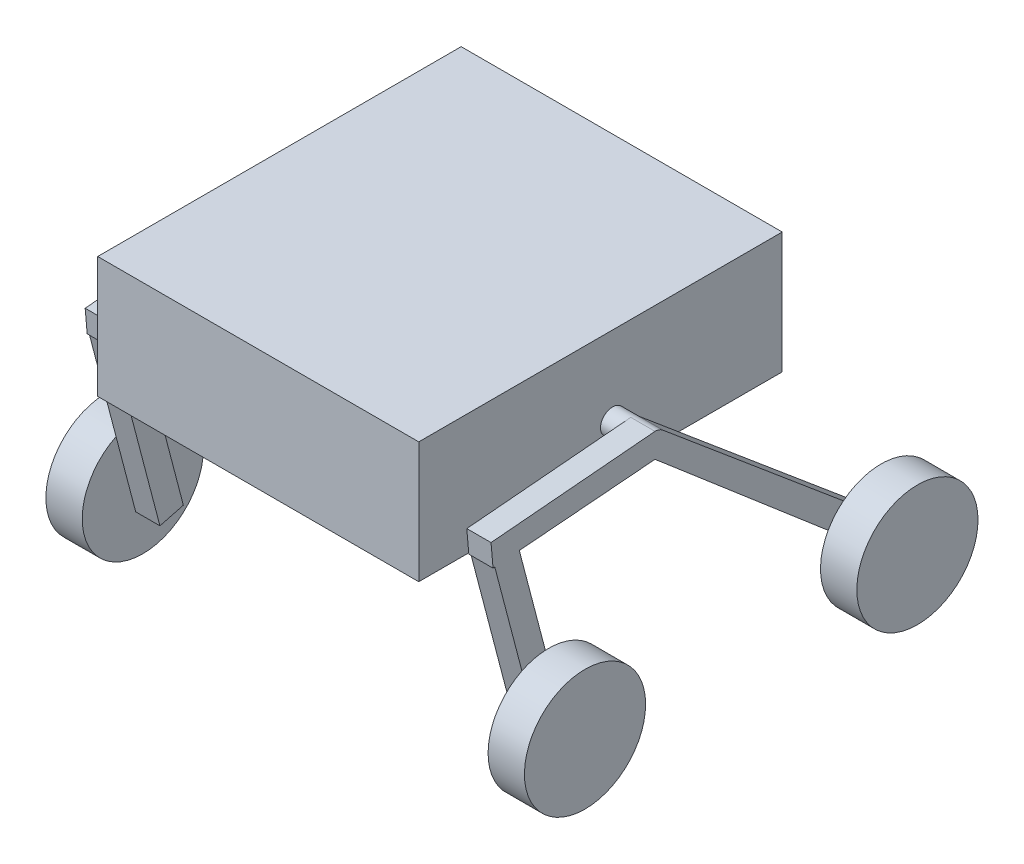
from build123d import *
from build123d.topology import SkipClean

# Parameters (mm, degrees)
SKETCH1_W           = 673.1
SKETCH1_H           = 762
BOSS_EXTRUDE1_DEPTH = 254
SKETCH2_R           = 25.4
BOSS_EXTRUDE2_DEPTH = 38.1
BOSS_EXTRUDE3_DEPTH = 50.8
SKETCH4_R           = 127
BOSS_EXTRUDE4_DEPTH = 76.2


with BuildPart() as part:
    # Sketch1 → Boss-Extrude1 (new body)
    with BuildSketch(Plane(origin=(0, 0, 0), x_dir=(1, 0, 0), z_dir=(0, 1, 0))):
        with Locations((336.55, 381)):
            Rectangle(SKETCH1_W, SKETCH1_H)
    extrude(amount=BOSS_EXTRUDE1_DEPTH)

    # Sketch2 → Boss-Extrude2 (add)
    with BuildSketch(Plane(origin=(673.1, 0, 0), x_dir=(0, 0, -1), z_dir=(1, 0, 0))):
        with Locations((406.4, 88.9)):
            Circle(SKETCH2_R)
    boss_extrude2 = extrude(amount=BOSS_EXTRUDE2_DEPTH)

    # Sketch3 → Boss-Extrude3 (add)
    with SkipClean():  # the faces are left unmerged after this step: merging them gives an invalid solid
        with BuildSketch(Plane(origin=(711.2, 0, 0), x_dir=(0, 0, -1), z_dir=(1, 0, 0))):
            with BuildLine():
                Line((422.726805286, 108.357528855), (925.855623983, -313.817677348))
                Line((925.855623983, -313.817677348), (909.528818697, -333.275206203))
                Line((909.528818697, -333.275206203), (893.202013411, -352.732735059))
                Line((893.202013411, -352.732735059), (406.4, 63.5))
                Line((406.4, 63.5), (121.876807164, 40.194732275))
                Line((121.876807164, 40.194732275), (217.686843741, -325.462787901))
                Line((217.686843741, -325.462787901), (193.116290848, -331.90079462))
                Line((193.116290848, -331.90079462), (168.545737954, -338.338801338))
                Line((168.545737954, -338.338801338), (70.465312804, 35.98362165))
                Line((70.465312804, 35.98362165), (66.845699755, 35.687139489))
                Line((66.845699755, 35.687139489), (64.804838024, 59.014295812))
                Line((64.804838024, 59.014295812), (62.591082159, 84.317641143))
                Line((62.591082159, 84.317641143), (406.4, 114.3))
                ThreePointArc((406.4, 114.3), (415.08731164, 112.768192568), (422.726805286, 108.357528855))
            make_face()
        boss_extrude3 = extrude(amount=BOSS_EXTRUDE3_DEPTH)

    # Sketch4 → Boss-Extrude4 (add)
    with SkipClean():  # the faces are left unmerged after this step: merging them gives an invalid solid
        with BuildSketch(Plane(origin=(762, 0, 0), x_dir=(0, 0, -1), z_dir=(1, 0, 0))):
            with Locations((183.45928077, -295.044965279)):
                Circle(SKETCH4_R)
            with Locations((880.342525414, -308.784998274)):
                Circle(SKETCH4_R)
        boss_extrude4 = extrude(amount=BOSS_EXTRUDE4_DEPTH)

    # Mirror1: Boss-Extrude2, Boss-Extrude3, Boss-Extrude4 across plane
    with SkipClean():  # the faces are left unmerged after this step: merging them gives an invalid solid
        add(boss_extrude2.mirror(Plane(origin=(336.55, 0, 0), x_dir=(0, 0, 1), z_dir=(1, 0, 0))))
        add(boss_extrude3.mirror(Plane(origin=(336.55, 0, 0), x_dir=(0, 0, 1), z_dir=(1, 0, 0))))
        add(boss_extrude4.mirror(Plane(origin=(336.55, 0, 0), x_dir=(0, 0, 1), z_dir=(1, 0, 0))))


solid = part.part
